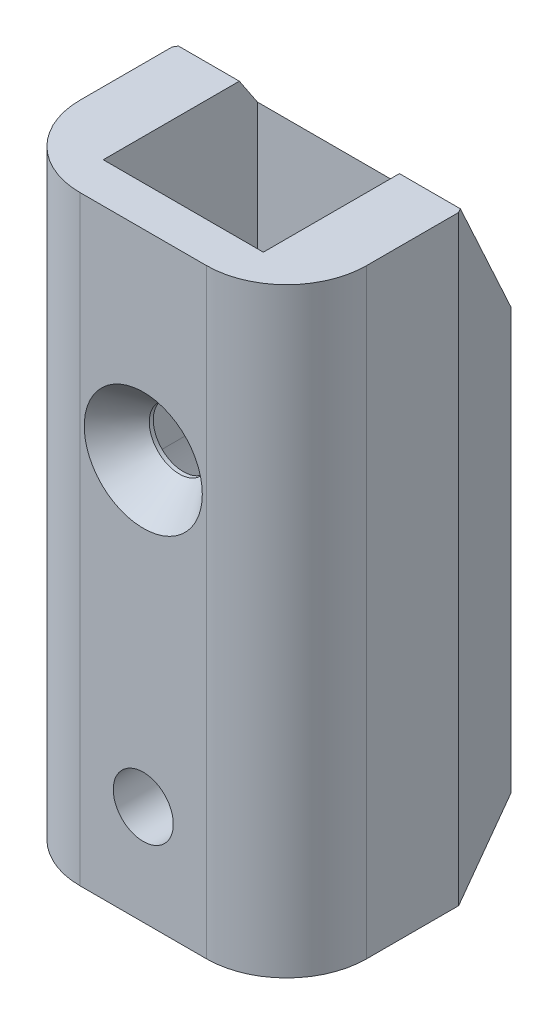
from build123d import *

# Parameters (mm, degrees)
CROQUIS1_R                 = 5
SALIENTE_EXTRUIR1_DEPTH    = 10
SALIENTE_EXTRUIR2_START    = 6.6
CROQUIS3_R                 = 1.5
SALIENTE_EXTRUIR2_DEPTH    = 2
SALIENTE_EXTRUIR3_START    = -3.3
CROQUIS3_3_R               = 1.5
SALIENTE_EXTRUIR3_DEPTH    = 2.9
SALIENTE_EXTRUIR4_START    = -1.1
SALIENTE_EXTRUIR4_DEPTH    = 5.1
SALIENTE_EXTRUIR5_START    = -6.2
SALIENTE_EXTRUIR5_DEPTH    = 14.8
CORTAR_EXTRUIR1_DEPTH      = 31
SALIENTE_EXTRUIR6_DEPTH    = 10
CROQUIS5_R                 = 1.5
CORTAR_EXTRUIR2_DEPTH      = 15.8
CHAFL_N1_SIZE              = 1.45
CHAFL_N1_SIZE2             = 1.8
CHAFL_N2_SIZE              = 1.45
CHAFL_N2_SIZE2             = 1.8
REDONDEO1_R                = 4
CORTAR_EXTRUIR3_DEPTH      = 8.159143338
CORTAR_EXTRUIR3_DEPTH_BACK = 8.159143338


with BuildPart() as part:
    # Croquis1 → Saliente-Extruir1 (new body)
    with BuildSketch(Plane(origin=(0, 0, 0), x_dir=(1, 0, 0), z_dir=(0, 1, 0))):
        Polygon((7.159143338, 0), (3.579571669, 6.2), (-3.579571669, 6.2), (-7.159143338, 0), (-3.579571669, -6.2), (3.579571669, -6.2), align=None)
        Circle(CROQUIS1_R, mode=Mode.SUBTRACT)
    extrude(amount=-SALIENTE_EXTRUIR1_DEPTH)



with BuildPart() as body_2:
    # Croquis3 → Saliente-Extruir2 (new body)
    with BuildSketch(Plane.XY.offset(SALIENTE_EXTRUIR2_START)):
        with BuildLine():
            Line((-4, 6), (-4, 20))
            Line((-4, 20), (4, 20))
            Line((4, 20), (4, 6))
            ThreePointArc((4, 6), (0, 2), (-4, 6))
        make_face()
        with BuildLine():
            ThreePointArc((3.2, 10), (0, 13.2), (-3.2, 10))
            Line((-3.2, 10), (-3.2, 6))
            ThreePointArc((-3.2, 6), (0, 2.8), (3.2, 6))
            Line((3.2, 6), (3.2, 10))
        make_face(mode=Mode.SUBTRACT)
        with BuildLine():
            Line((3.2, 6), (3.2, 10))
            ThreePointArc((3.2, 10), (0, 13.2), (-3.2, 10))
            Line((-3.2, 10), (-3.2, 6))
            ThreePointArc((-3.2, 6), (0, 2.8), (3.2, 6))
        make_face()
        with Locations((0, 6)):
            Circle(CROQUIS3_R, mode=Mode.SUBTRACT)
        with Locations((0, 10)):
            Circle(CROQUIS3_R, mode=Mode.SUBTRACT)
        with Locations((0, 6)):
            Circle(CROQUIS3_R)
    extrude(amount=SALIENTE_EXTRUIR2_DEPTH)


with BuildPart() as body_3:
    # Croquis3_3 → Saliente-Extruir3 (new body)
    with BuildSketch(Plane.XY.offset(SALIENTE_EXTRUIR3_START)):
        with BuildLine():
            Line((3.2, 6), (3.2, 10))
            ThreePointArc((3.2, 10), (0, 13.2), (-3.2, 10))
            Line((-3.2, 10), (-3.2, 6))
            ThreePointArc((-3.2, 6), (0, 2.8), (3.2, 6))
        make_face()
        with Locations((0, 6)):
            Circle(CROQUIS3_3_R, mode=Mode.SUBTRACT)
        with Locations((0, 10)):
            Circle(CROQUIS3_3_R, mode=Mode.SUBTRACT)
        with Locations((0, 10)):
            Circle(CROQUIS3_3_R)
    extrude(amount=-SALIENTE_EXTRUIR3_DEPTH)

    # Croquis3_4 → Saliente-Extruir4 (add)
    with BuildSketch(Plane.XY.offset(SALIENTE_EXTRUIR4_START)):
        with BuildLine():
            Line((-4, 6), (-4, 20))
            Line((-4, 20), (4, 20))
            Line((4, 20), (4, 6))
            ThreePointArc((4, 6), (0, 2), (-4, 6))
        make_face()
        with BuildLine():
            ThreePointArc((3.2, 10), (0, 13.2), (-3.2, 10))
            Line((-3.2, 10), (-3.2, 6))
            ThreePointArc((-3.2, 6), (0, 2.8), (3.2, 6))
            Line((3.2, 6), (3.2, 10))
        make_face(mode=Mode.SUBTRACT)
    extrude(amount=-SALIENTE_EXTRUIR4_DEPTH)


with BuildPart() as part_1:
    add(part.part)

    add(body_2.part)  # Saliente-Extruir5 merges body 2

    add(body_3.part)  # Saliente-Extruir5 merges body 3
    # Croquis3_6 → Saliente-Extruir5 (add)
    with BuildSketch(Plane.XY.offset(SALIENTE_EXTRUIR5_START)):
        with BuildLine():
            ThreePointArc((-4, 6), (0, 2), (4, 6))
            Line((4, 6), (4, 20))
            Line((4, 20), (7.159143338, 20))
            Line((7.159143338, 20), (7.159143338, 0))
            Line((7.159143338, 0), (-7.159143338, 0))
            Line((-7.159143338, 0), (-7.159143338, 20))
            Line((-7.159143338, 20), (-4, 20))
            Line((-4, 20), (-4, 6))
        make_face()
    extrude(amount=SALIENTE_EXTRUIR5_DEPTH)

    # Croquis4 → Cortar-Extruir1 (cut, through all)
    with BuildSketch(Plane(origin=(0, -10, 0), x_dir=(-1, 0, 0), z_dir=(0, -1, 0))):
        Polygon((7.159143338, 6.2), (7.159143338, 0), (3.579571669, 6.2), align=None)
        Polygon((-7.159143338, 6.2), (-3.579571669, 6.2), (-7.159143338, 0), align=None)
    extrude(amount=-CORTAR_EXTRUIR1_DEPTH, mode=Mode.SUBTRACT)

    # Croquis4_3 → Saliente-Extruir6 (add)
    with BuildSketch(Plane(origin=(0, -10, 0), x_dir=(-1, 0, 0), z_dir=(0, -1, 0))):
        Polygon((-7.159143338, -8.6), (7.159143338, -8.6), (7.159143338, 0), (3.579571669, -6.2), (-3.579571669, -6.2), (-7.159143338, 0), align=None)
    extrude(amount=-SALIENTE_EXTRUIR6_DEPTH)

    # Croquis5 → Cortar-Extruir2 (cut, through all)
    with BuildSketch(Plane(origin=(0, 0, -6.2), x_dir=(-1, 0, 0), z_dir=(0, 0, -1))):
        with Locations((0, -5)):
            Circle(CROQUIS5_R)
    extrude(amount=-CORTAR_EXTRUIR2_DEPTH, mode=Mode.SUBTRACT)

    # Chaflán1
    chafl_n1_edges = [part_1.edges().sort_by_distance(p)[0] for p in [
        (-1.5, 10, 8.6),
    ]]
    chafl_n1_side = [part_1.faces().sort_by_distance(p)[0] for p in [
        (0, 5.085079308, 8.6),
    ]]
    chamfer(chafl_n1_edges, length=CHAFL_N1_SIZE, length2=CHAFL_N1_SIZE2, reference=chafl_n1_side[0])

    # Chaflán2
    chafl_n2_edges = [part_1.edges().sort_by_distance(p)[0] for p in [
        (-1.5, 6, -6.2),
    ]]
    chafl_n2_side = [part_1.faces().sort_by_distance(p)[0] for p in [
        (-1.5, 6, -4.75),
    ]]
    chamfer(chafl_n2_edges, length=CHAFL_N2_SIZE, length2=CHAFL_N2_SIZE2, reference=chafl_n2_side[0])

    # Redondeo1
    redondeo1_edges = [part_1.edges().sort_by_distance(p)[0] for p in [
        (7.159143338, 5, 8.6),
        (-7.159143338, 5, 8.6),
    ]]
    fillet(redondeo1_edges, radius=REDONDEO1_R)

    # Croquis6 → Cortar-Extruir3 (cut, two sides)
    with BuildSketch(Plane(origin=(0, 0, 0), x_dir=(0, 0, -1), z_dir=(1, 0, 0))) as cortar_extruir3_sk:
        Polygon((6.2, 20), (0.2, 20), (6.2, 11), align=None)
    extrude(amount=CORTAR_EXTRUIR3_DEPTH, mode=Mode.SUBTRACT)
    extrude(cortar_extruir3_sk.sketch, amount=-CORTAR_EXTRUIR3_DEPTH_BACK, mode=Mode.SUBTRACT)


solid = part_1.part
